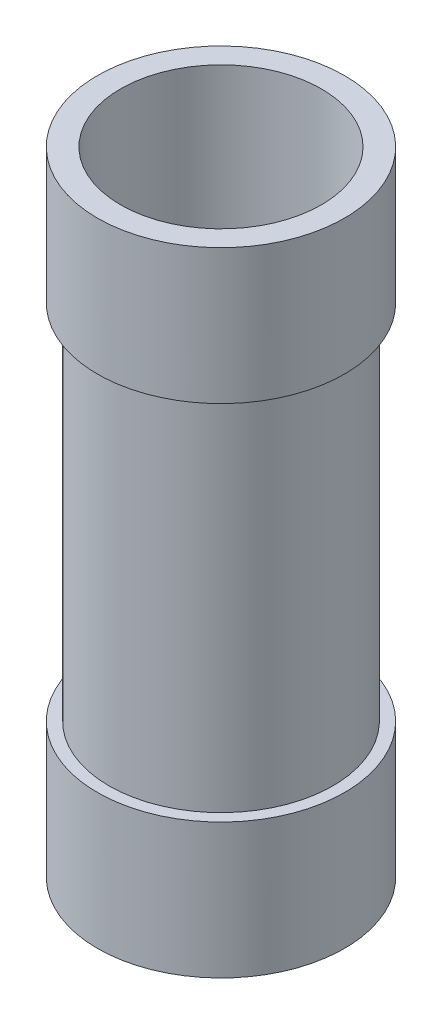
from build123d import *

# Parameters (mm, degrees)
SKETCH3_R           = 37.5
SKETCH3_R_2         = 30.5
BOSS_EXTRUDE1_DEPTH = 192
CUT_EXTRUDE3_START  = -41
SKETCH7_R           = 39
SKETCH7_R_2         = 34
CUT_EXTRUDE3_DEPTH  = 110


with BuildPart() as part:
    # Sketch3 → Boss-Extrude1 (new body)
    with BuildSketch(Plane(origin=(0, 0, 0), x_dir=(1, 0, 0), z_dir=(0, 1, 0))):
        Circle(SKETCH3_R)
        Circle(SKETCH3_R_2, mode=Mode.SUBTRACT)
    extrude(amount=BOSS_EXTRUDE1_DEPTH)

    # Sketch7 → Cut-Extrude3 (cut)
    with BuildSketch(Plane(origin=(0, 0, 0), x_dir=(-1, 0, 0), z_dir=(0, -1, 0)).offset(CUT_EXTRUDE3_START)):
        Circle(SKETCH7_R)
        Circle(SKETCH7_R_2, mode=Mode.SUBTRACT)
    extrude(amount=-CUT_EXTRUDE3_DEPTH, mode=Mode.SUBTRACT)


solid = part.part
